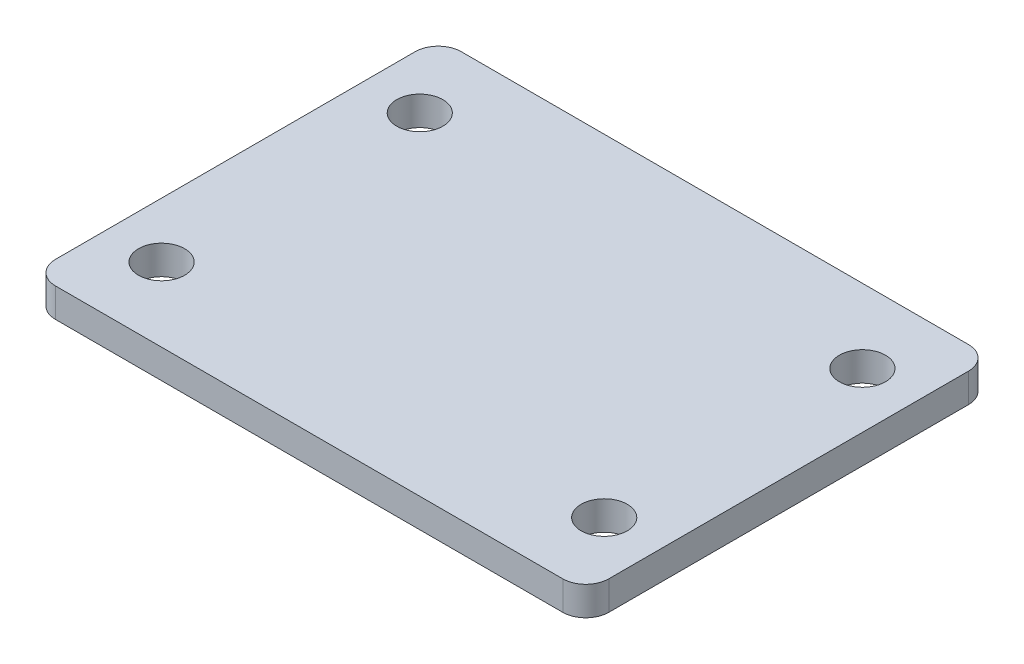
from build123d import *

# Parameters (mm, degrees)
SKETCH1_R           = 3.96875
BOSS_EXTRUDE1_DEPTH = 5


with BuildPart() as part:
    # Sketch1 → Boss-Extrude1 (new body)
    with BuildSketch(Plane(origin=(0, 0, 0), x_dir=(1, 0, 0), z_dir=(0, 1, 0))):
        with BuildLine():
            Line((-43.6626, 34.925), (43.6626, 34.925))
            ThreePointArc((43.6626, 34.925), (46.46443991, 33.76443991), (47.625, 30.9626))
            Line((47.625, 30.9626), (47.625, -30.9626))
            ThreePointArc((47.625, -30.9626), (46.46443991, -33.76443991), (43.6626, -34.925))
            Line((43.6626, -34.925), (-43.6626, -34.925))
            ThreePointArc((-43.6626, -34.925), (-46.46443991, -33.76443991), (-47.625, -30.9626))
            Line((-47.625, -30.9626), (-47.625, 30.9626))
            ThreePointArc((-47.625, 30.9626), (-46.46443991, 33.76443991), (-43.6626, 34.925))
        make_face()
        with Locations((-38.1, 22.225)):
            Circle(SKETCH1_R, mode=Mode.SUBTRACT)
        with Locations((-38.1, -22.225)):
            Circle(SKETCH1_R, mode=Mode.SUBTRACT)
        with Locations((38.1, -22.225)):
            Circle(SKETCH1_R, mode=Mode.SUBTRACT)
        with Locations((38.1, 22.225)):
            Circle(SKETCH1_R, mode=Mode.SUBTRACT)
    extrude(amount=BOSS_EXTRUDE1_DEPTH)


solid = part.part
